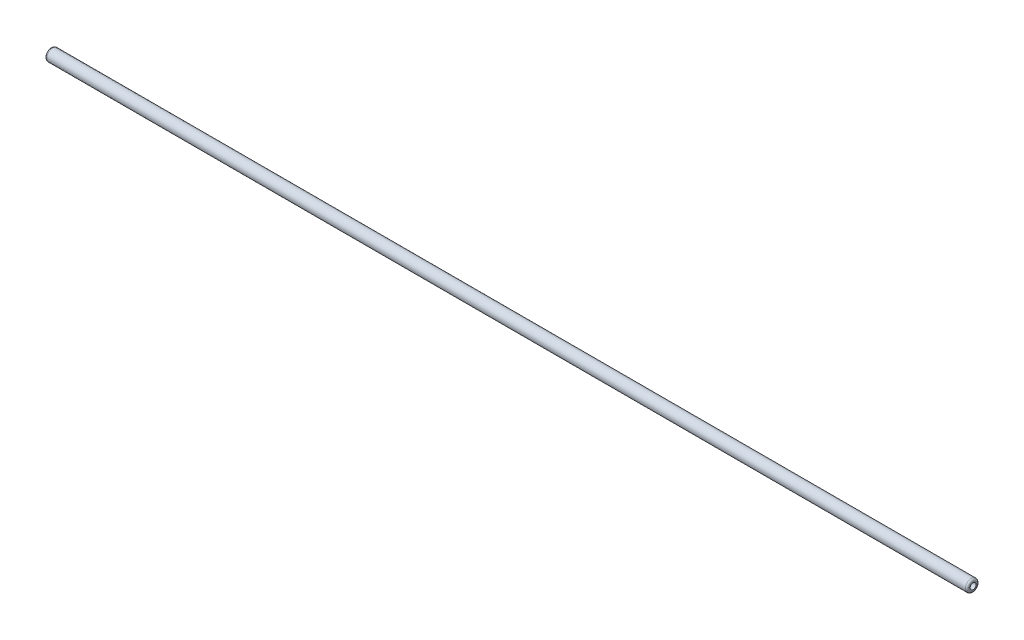
from build123d import *

# Parameters (mm, degrees)
SKETCH_1_R        = 7.9375
SKETCH_1_R_2      = 3.975
EXTRUDE_1_DEPTH   = 614.3625
FILLET_1_R        = 2.5
MOVE_BODY_1_ANGLE = 90


with BuildPart() as part:
    # 스케치1 → 보스-돌출1 (new body, symmetric)
    with BuildSketch(Plane(origin=(0, 0, 0), x_dir=(1, 0, 0), z_dir=(0, 1, 0))):
        Circle(SKETCH_1_R)
        Circle(SKETCH_1_R_2, mode=Mode.SUBTRACT)
    extrude(amount=EXTRUDE_1_DEPTH, both=True)

    # 필렛1
    fillet_1_edges = [part.edges().sort_by_distance(p)[0] for p in [
        (-7.9375, -614.3625, 0),
        (-7.9375, 614.3625, 0),
    ]]
    fillet(fillet_1_edges, radius=FILLET_1_R)


with BuildPart() as part_1:
    # Move Body 1: moved
    add(part.part.rotate(Axis((0, 0, 0), (0, 0, 1)), MOVE_BODY_1_ANGLE))


solid = part_1.part
